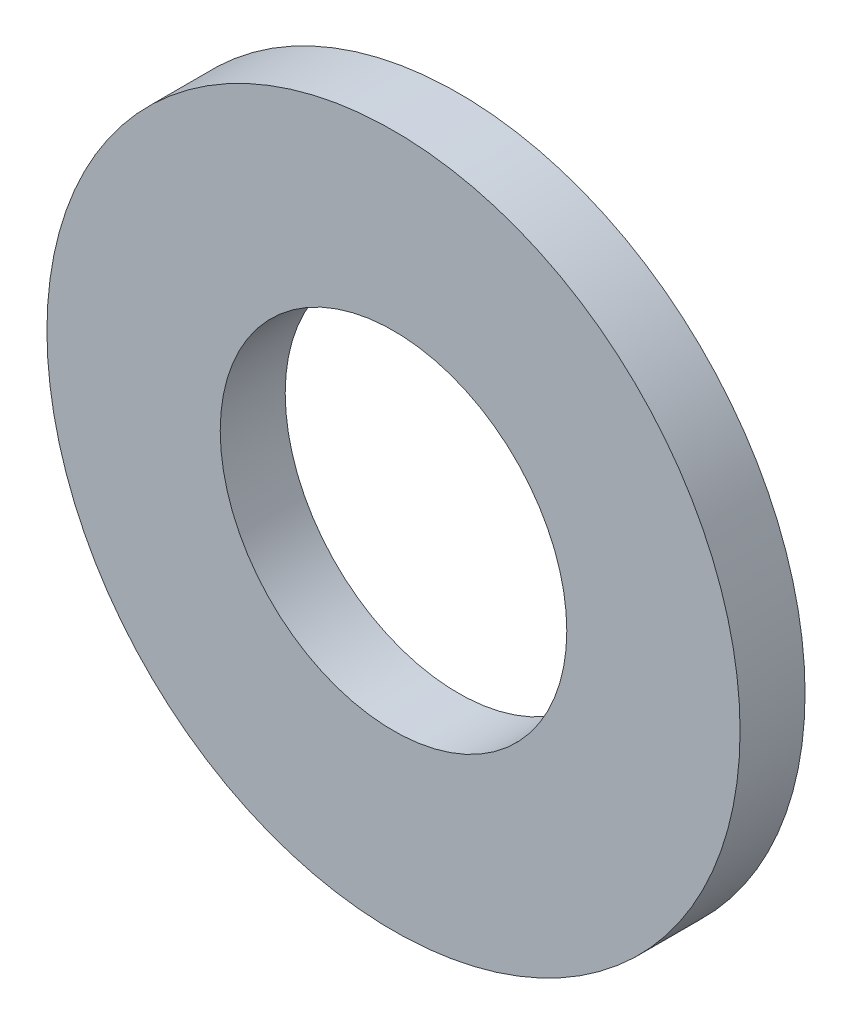
from build123d import *

# Parameters (mm, degrees)
SKETCH1_R           = 8
SKETCH1_R_2         = 4
BOSS_EXTRUDE1_DEPTH = 1.5


with BuildPart() as part:
    # Sketch1 → Boss-Extrude1 (new body)
    with BuildSketch(Plane.XY):
        Circle(SKETCH1_R)
        Circle(SKETCH1_R_2, mode=Mode.SUBTRACT)
    extrude(amount=BOSS_EXTRUDE1_DEPTH)


solid = part.part
